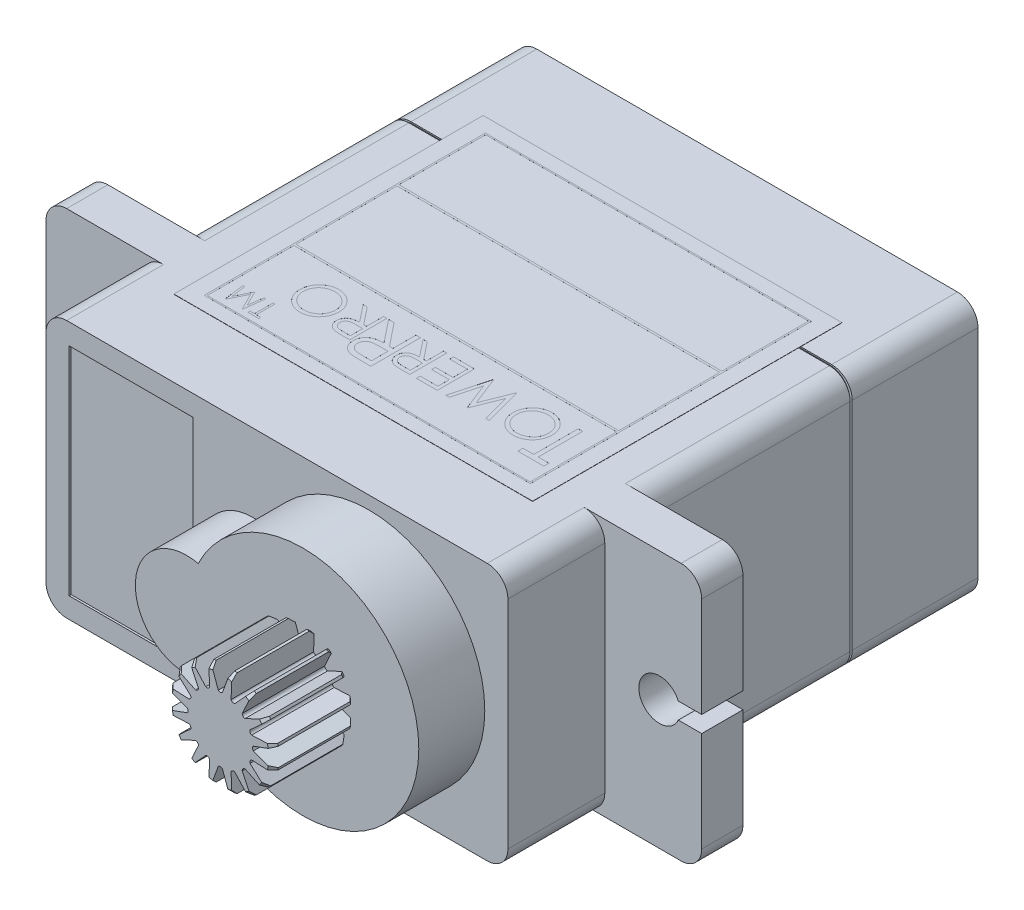
from build123d import *

# Parameters (mm, degrees)
IZIM1_W                      = 22.4
IZIM1_H                      = 12.5
IZIM1_W_2                    = 20.16
IZIM1_H_2                    = 11.25
Y_KSEKLIK_EKSTR_ZYON1_DEPTH  = 16.1
IZIM2_W                      = 22.4
IZIM2_H                      = 12.5
IZIM2_W_2                    = 20.16
IZIM2_H_2                    = 11.25
Y_KSEKLIK_EKSTR_ZYON2_DEPTH  = 6.7
Y_KSEKLIK_EKSTR_ZYON3_DEPTH  = 2
Y_KSEKLIK_EKSTR_ZYON4_DEPTH  = 26
IZIM4_W                      = 20.16
IZIM4_H                      = 11.25
KES_EKSTR_ZYON1_DEPTH        = 32
IZIM4_2_W                    = 20.16
IZIM4_2_H                    = 11.25
Y_KSEKLIK_EKSTR_ZYON5_DEPTH  = 2
IZIM6_W                      = 6
IZIM6_H                      = 10.5
KES_EKSTR_ZYON2_DEPTH        = 0.1
Y_KSEKLIK_EKSTR_ZYON6_START  = -0.1
IZIM7_W                      = 20.16
IZIM7_H                      = 11.25
Y_KSEKLIK_EKSTR_ZYON6_DEPTH  = 2
RADYUS1_R                    = 1
KES_EKSTR_ZYON3_START        = -6
KES_EKSTR_ZYON3_DEPTH        = 0.1
IZIM10_W                     = 17.4
IZIM10_H                     = 2.1
Y_KSEKLIK_EKSTR_ZYON7_DEPTH  = 0.01
IZIM11_W                     = 15.8166
IZIM11_H                     = 13.635
IZIM11_W_2                   = 15.66
IZIM11_H_2                   = 4.2
IZIM11_H_3                   = 4.9
Y_KSEKLIK_EKSTR_ZYON8_DEPTH  = 0.001
KES_EKSTR_ZYON4_DEPTH        = 0.001
IZIM13_R                     = 0.5
Y_KSEKLIK_EKSTR_ZYON9_DEPTH  = 3.8
IZIM15_R                     = 2.6
Y_KSEKLIK_EKSTR_ZYON10_DEPTH = 4
PAH1_SIZE                    = 0.25
CUT_EXTRUDE4_DEPTH           = 4
CIRPATTERN1_COUNT            = 16


with BuildPart() as part:
    # izim1 → Y_kseklik-Ekstr_zyon1 (new body)
    with BuildSketch(Plane.XY):
        with Locations((11.2, 6.25)):
            Rectangle(IZIM1_W, IZIM1_H)
        with Locations((11.2, 6.25)):
            Rectangle(IZIM1_W_2, IZIM1_H_2, mode=Mode.SUBTRACT)
    extrude(amount=Y_KSEKLIK_EKSTR_ZYON1_DEPTH)

    # izim2 → Y_kseklik-Ekstr_zyon2 (add)
    with BuildSketch(Plane.XY.offset(16.1)):
        with Locations((11.2, 6.25)):
            Rectangle(IZIM2_W, IZIM2_H)
        with Locations((11.2, 6.25)):
            Rectangle(IZIM2_W_2, IZIM2_H_2, mode=Mode.SUBTRACT)
    extrude(amount=Y_KSEKLIK_EKSTR_ZYON2_DEPTH)

    # izim2_5 → Y_kseklik-Ekstr_zyon3 (add)
    with BuildSketch(Plane.XY.offset(16.1)):
        with BuildLine():
            ThreePointArc((-3.566709048, 5.85), (-1.649822276, 6.25), (-3.566709048, 6.65))
            Line((-3.566709048, 6.65), (-4.7, 6.65))
            Line((-4.7, 6.65), (-4.7, 12.5))
            Line((-4.7, 12.5), (0, 12.5))
            Line((0, 12.5), (0, 0))
            Line((0, 0), (-4.7, 0))
            Line((-4.7, 0), (-4.7, 5.85))
            Line((-4.7, 5.85), (-3.566709048, 5.85))
        make_face()
        with BuildLine():
            Line((27.1, 5.85), (25.966709048, 5.85))
            ThreePointArc((25.966709048, 5.85), (24.049822276, 6.25), (25.966709048, 6.65))
            Line((25.966709048, 6.65), (27.1, 6.65))
            Line((27.1, 6.65), (27.1, 12.5))
            Line((27.1, 12.5), (22.4, 12.5))
            Line((22.4, 12.5), (22.4, 0))
            Line((22.4, 0), (27.1, 0))
            Line((27.1, 0), (27.1, 5.85))
        make_face()
    extrude(amount=Y_KSEKLIK_EKSTR_ZYON3_DEPTH)



with BuildPart() as body_2:
    # izim3 → Y_kseklik-Ekstr_zyon4 (new body)
    with BuildSketch(Plane(origin=(0, 0, 0), x_dir=(-1, 0, 0), z_dir=(0, 0, -1))):
        with BuildLine():
            ThreePointArc((-10.583916669, 8.684078645), (-21.28, 6.25), (-10.583916669, 3.815921355))
            ThreePointArc((-10.583916669, 3.815921355), (-7.533690219, 6.25), (-10.583916669, 8.684078645))
        make_face()
    extrude(amount=-Y_KSEKLIK_EKSTR_ZYON4_DEPTH)

    # izim4 → Kes-Ekstr_zyon1 (cut)
    with BuildSketch(Plane.XY.offset(22.8)):
        with Locations((11.2, 6.25)):
            Rectangle(IZIM4_W, IZIM4_H)
    extrude(amount=-KES_EKSTR_ZYON1_DEPTH, mode=Mode.SUBTRACT)


with BuildPart() as part_1:
    add(part.part)

    add(body_2.part)  # Y_kseklik-Ekstr_zyon5 merges body 2
    # izim4_2 → Y_kseklik-Ekstr_zyon5 (add)
    with BuildSketch(Plane.XY.offset(22.8)):
        with Locations((11.2, 6.25)):
            Rectangle(IZIM4_2_W, IZIM4_2_H)
    extrude(amount=-Y_KSEKLIK_EKSTR_ZYON5_DEPTH)

    # izim6 → Kes-Ekstr_zyon2 (cut)
    with BuildSketch(Plane.XY.offset(22.8)):
        with Locations((4.120596884, 6.247127185)):
            Rectangle(IZIM6_W, IZIM6_H)
    extrude(amount=-KES_EKSTR_ZYON2_DEPTH, mode=Mode.SUBTRACT)

    # izim7 → Y_kseklik-Ekstr_zyon6 (add)
    with BuildSketch(Plane(origin=(0, 0, 0), x_dir=(-1, 0, 0), z_dir=(0, 0, -1)).offset(Y_KSEKLIK_EKSTR_ZYON6_START)):
        with Locations((-11.2, 6.25)):
            Rectangle(IZIM7_W, IZIM7_H)
    extrude(amount=-Y_KSEKLIK_EKSTR_ZYON6_DEPTH)

    # Radyus1
    radyus1_edges = [part_1.edges().sort_by_distance(p)[0] for p in [
        (0, 0, 8.05),
        (0, 12.5, 8.05),
        (-4.7, 0, 17.1),
        (-4.7, 12.5, 17.1),
        (22.4, 12.5, 8.05),
        (22.4, 0, 8.05),
        (0, 12.5, 20.45),
        (22.4, 12.5, 20.45),
        (22.4, 0, 20.45),
        (27.1, 12.5, 17.1),
        (0, 0, 20.45),
        (27.1, 0, 17.1),
    ]]
    fillet(radyus1_edges, radius=RADYUS1_R)

    # izim9 → Kes-Ekstr_zyon3 (cut)
    with BuildSketch(Plane(origin=(0, 0, 0.1), x_dir=(-1, 0, 0), z_dir=(0, 0, -1)).offset(KES_EKSTR_ZYON3_START)):
        with BuildLine():
            Line((-21.4, 12.5), (-1, 12.5))
            ThreePointArc((-1, 12.5), (-0.292893219, 12.207106781), (0, 11.5))
            Line((0, 11.5), (0, 1))
            ThreePointArc((0, 1), (-0.292893219, 0.292893219), (-1, 0))
            Line((-1, 0), (-21.4, 0))
            ThreePointArc((-21.4, 0), (-22.107106781, 0.292893219), (-22.4, 1))
            Line((-22.4, 1), (-22.4, 11.5))
            ThreePointArc((-22.4, 11.5), (-22.107106781, 12.207106781), (-21.4, 12.5))
        make_face()
        with BuildLine():
            Line((-22.288, 1.0525), (-22.288, 11.4475))
            ThreePointArc((-22.288, 11.4475), (-21.998035713, 12.147535713), (-21.298, 12.4375))
            Line((-21.298, 12.4375), (-1.102, 12.4375))
            ThreePointArc((-1.102, 12.4375), (-0.401964287, 12.147535713), (-0.112, 11.4475))
            Line((-0.112, 11.4475), (-0.112, 1.0525))
            ThreePointArc((-0.112, 1.0525), (-0.401964287, 0.352464287), (-1.102, 0.0625))
            Line((-1.102, 0.0625), (-21.298, 0.0625))
            ThreePointArc((-21.298, 0.0625), (-21.998035713, 0.352464287), (-22.288, 1.0525))
        make_face(mode=Mode.SUBTRACT)
    extrude(amount=-KES_EKSTR_ZYON3_DEPTH, mode=Mode.SUBTRACT)

    # izim10 → Y_kseklik-Ekstr_zyon7 (add)
    with BuildSketch(Plane(origin=(0, 12.5, 0), x_dir=(1, 0, 0), z_dir=(0, 1, 0))):
        Polygon((2.5, -19.1), (19.9, -19.1), (19.9, -18.1), (19.9, -6.2), (2.5, -6.2), align=None)
        with Locations((11.2, -5.15)):
            Rectangle(IZIM10_W, IZIM10_H)
    extrude(amount=Y_KSEKLIK_EKSTR_ZYON7_DEPTH)

    # izim11 → Y_kseklik-Ekstr_zyon8 (add)
    with BuildSketch(Plane(origin=(0, 12.51, 0), x_dir=(1, 0, 0), z_dir=(0, 1, 0))):
        with Locations((11.2, -11.6)):
            Rectangle(IZIM11_W, IZIM11_H)
        with Locations((11.2, -16.25)):
            Rectangle(IZIM11_W_2, IZIM11_H_2, mode=Mode.SUBTRACT)
        with Locations((11.2, -6.95)):
            Rectangle(IZIM11_W_2, IZIM11_H_2, mode=Mode.SUBTRACT)
        with Locations((11.2, -11.6)):
            Rectangle(IZIM11_W_2, IZIM11_H_3, mode=Mode.SUBTRACT)
    extrude(amount=Y_KSEKLIK_EKSTR_ZYON8_DEPTH)

    # izim12 → Kes-Ekstr_zyon4 (cut)
    with BuildSketch(Plane(origin=(0, 12.51, 0), x_dir=(1, 0, 0), z_dir=(0, 1, 0))):
        Polygon((18.179849752, -17.10955999), (18.702926675, -17.10955999), (18.702926675, -17.355713837), (17.441388213, -17.355713837), (17.441388213, -17.10955999), (17.964465136, -17.10955999), (17.964465136, -14.955713837), (18.179849752, -14.955713837), align=None)
        with BuildLine():
            add(Edge.make_bspline(
                [(17.596123598, -15.847781144), (17.596600402, -15.890352652), (17.592054157, -15.953769235), (17.579172047, -16.037109108), (17.565460452, -16.098068862), (17.547741173, -16.157819698), (17.525913504, -16.216240052), (17.500896874, -16.27381097), (17.47111171, -16.329436818), (17.438615056, -16.383204893), (17.40318076, -16.434442874), (17.36456171, -16.482235511), (17.323309582, -16.527350755), (17.278853352, -16.569018591), (17.231862086, -16.608147478), (17.182089902, -16.644332354), (17.129458087, -16.676813285), (17.075308504, -16.706647276), (17.019248311, -16.731556708), (16.962460266, -16.753571424), (16.904444362, -16.771073448), (16.845334046, -16.784976123), (16.764497886, -16.797770734), (16.702885675, -16.802359627), (16.661508214, -16.801867683)],
                knots=[0, 0, 0, 0, 0.085881169, 0.128132386, 0.170168405, 0.211938097, 0.253861187, 0.296020311, 0.338574299, 0.381150423, 0.422820599, 0.464244847, 0.505120974, 0.546150251, 0.587164454, 0.62852183, 0.670271074, 0.711969505, 0.753242069, 0.794029495, 0.834869589, 0.875486283, 0.916539236, 1, 1, 1, 1], degree=3))
            add(Edge.make_bspline(
                [(16.661508214, -16.801867683), (16.59608632, -16.801676694), (16.499095745, -16.794133942), (16.374523585, -16.765278498), (16.28650177, -16.735345664), (16.202847856, -16.696490934), (16.123298834, -16.649331281), (16.048127766, -16.593391403), (15.977529104, -16.530002392), (15.913361965, -16.460324424), (15.857525352, -16.385520266), (15.810006102, -16.307095468), (15.771170508, -16.224539268), (15.740694657, -16.138220427), (15.712097556, -16.015819013), (15.703687695, -15.920728943), (15.703815906, -15.85643499)],
                knots=[0, 0, 0, 0, 0.13073763, 0.193341164, 0.25498957, 0.316108392, 0.377251257, 0.43938486, 0.502966344, 0.566515184, 0.628263548, 0.689117745, 0.749366545, 0.810186161, 0.871621029, 1, 1, 1, 1], degree=3))
            add(Edge.make_bspline(
                [(15.703815906, -15.85643499), (15.703693647, -15.792625776), (15.712093484, -15.698110766), (15.740788506, -15.576521041), (15.770793046, -15.490327904), (15.809657294, -15.40793808), (15.8572513, -15.329458419), (15.912962472, -15.25443614), (15.976866522, -15.184418979), (16.046650505, -15.120245908), (16.120992518, -15.063515201), (16.199802813, -15.016257957), (16.281851761, -14.97684261), (16.36795434, -14.947026989), (16.488998428, -14.917475402), (16.583439396, -14.909591987), (16.647085137, -14.90955999)],
                knots=[0, 0, 0, 0, 0.128576319, 0.190331218, 0.251392307, 0.312186107, 0.37359078, 0.436091904, 0.500231152, 0.564354845, 0.626953074, 0.688357747, 0.749255231, 0.810087631, 0.871663616, 1, 1, 1, 1], degree=3))
            add(Edge.make_bspline(
                [(16.647085137, -14.90955999), (16.711376806, -14.909424964), (16.806590582, -14.917865065), (16.929052902, -14.946469582), (17.015705008, -14.976547628), (17.098377514, -15.015325029), (17.177062189, -15.062963513), (17.25185363, -15.119102379), (17.32199081, -15.182956243), (17.386086472, -15.252606418), (17.442463171, -15.326850795), (17.489826856, -15.404983364), (17.528621071, -15.486681964), (17.559263944, -15.571735652), (17.587693085, -15.691760407), (17.59632315, -15.784906211), (17.596123598, -15.847781144)],
                knots=[0, 0, 0, 0, 0.129754547, 0.192083828, 0.253475092, 0.314589033, 0.376095281, 0.438844932, 0.503090279, 0.567320043, 0.629681905, 0.690980548, 0.751436286, 0.811992743, 0.87314184, 1, 1, 1, 1], degree=3))
        make_face()
        with BuildLine():
            add(Edge.make_bspline(
                [(15.865354368, -15.856795567), (15.864899048, -15.89141212), (15.868641252, -15.942755255), (15.879171493, -16.010004715), (15.890346538, -16.058689287), (15.904776872, -16.106054156), (15.922563437, -16.152055361), (15.943539052, -16.196864151), (15.967611793, -16.240369751), (15.99467128, -16.28211691), (16.024240123, -16.322026161), (16.056826592, -16.359351378), (16.091508167, -16.395001393), (16.129118664, -16.42826316), (16.169664675, -16.459008053), (16.212136541, -16.48862175), (16.257495186, -16.514828979), (16.304137663, -16.539157113), (16.352047102, -16.559895927), (16.400624452, -16.57780924), (16.449934394, -16.592104184), (16.49989249, -16.60342163), (16.567632767, -16.613847542), (16.619073115, -16.617732743), (16.653575522, -16.617252298)],
                knots=[0, 0, 0, 0, 0.085123374, 0.126463518, 0.167440062, 0.207960217, 0.248230142, 0.288727612, 0.329644311, 0.370508574, 0.411096706, 0.451783902, 0.492367721, 0.533444523, 0.575218486, 0.617559484, 0.66078721, 0.704052373, 0.746976364, 0.789184872, 0.831405817, 0.873247812, 0.915172343, 1, 1, 1, 1], degree=3))
            add(Edge.make_bspline(
                [(16.653575522, -16.617252298), (16.687597892, -16.617729343), (16.738323725, -16.61385477), (16.805096503, -16.603410733), (16.854236619, -16.592166296), (16.902663877, -16.577730089), (16.950432748, -16.559910889), (16.997585697, -16.539106248), (17.043691586, -16.514957261), (17.088014073, -16.487888616), (17.130819477, -16.459349311), (17.170473007, -16.427721735), (17.207740586, -16.394178764), (17.242531795, -16.358258555), (17.274851287, -16.320225718), (17.304667209, -16.279908069), (17.331622211, -16.237473595), (17.355609865, -16.193158656), (17.377087479, -16.147810533), (17.39488998, -16.10089618), (17.40899825, -16.052708629), (17.420949959, -16.003459246), (17.431151996, -15.935388431), (17.435136733, -15.883495399), (17.434585137, -15.848502298)],
                knots=[0, 0, 0, 0, 0.083634277, 0.124967906, 0.166226326, 0.207589577, 0.24923634, 0.291611976, 0.334345341, 0.377209532, 0.419377167, 0.46085975, 0.501906639, 0.542695883, 0.583825813, 0.624645074, 0.666000921, 0.707429689, 0.748581948, 0.789397994, 0.830761245, 0.872086406, 0.914004329, 1, 1, 1, 1], degree=3))
            add(Edge.make_bspline(
                [(17.434585137, -15.848502298), (17.434750827, -15.797346282), (17.42762467, -15.721663344), (17.403842094, -15.624244722), (17.378499799, -15.555401087), (17.346126628, -15.489531054), (17.306649283, -15.426890951), (17.259693895, -15.367499274), (17.206388879, -15.311798069), (17.148101031, -15.26097781), (17.086237636, -15.216305818), (17.021288072, -15.178711215), (16.953626686, -15.147273412), (16.882675875, -15.123624642), (16.783067773, -15.100683796), (16.705786175, -15.09374018), (16.653575522, -15.094175375)],
                knots=[0, 0, 0, 0, 0.1268942, 0.187738963, 0.248419712, 0.308585774, 0.369580252, 0.4318217, 0.49617186, 0.56065739, 0.623491454, 0.685244918, 0.746642893, 0.808335087, 0.870491415, 1, 1, 1, 1], degree=3))
            add(Edge.make_bspline(
                [(16.653575522, -15.094175375), (16.61827604, -15.094022944), (16.565574476, -15.097066102), (16.496405554, -15.107625162), (16.445877829, -15.11893103), (16.396319697, -15.132912391), (16.347883036, -15.150252338), (16.300575356, -15.171030097), (16.254196299, -15.194223032), (16.209750432, -15.220380406), (16.167742487, -15.249120925), (16.127896212, -15.279675067), (16.090696657, -15.312975122), (16.056050694, -15.348592326), (16.024308826, -15.386786075), (15.994506805, -15.426801694), (15.967740863, -15.469225384), (15.943424136, -15.513189671), (15.922577474, -15.558669814), (15.904764642, -15.605377795), (15.890402682, -15.653359562), (15.879163004, -15.702504585), (15.868647916, -15.7702394), (15.864895994, -15.821938569), (15.865354368, -15.856795567)],
                knots=[0, 0, 0, 0, 0.086551414, 0.129197693, 0.17146334, 0.213449527, 0.255404662, 0.297514824, 0.340092799, 0.382506193, 0.423874281, 0.464849866, 0.505557411, 0.546205151, 0.586586979, 0.627264633, 0.668477012, 0.709503453, 0.750388823, 0.791063273, 0.832000674, 0.873115963, 0.914597308, 1, 1, 1, 1], degree=3))
        make_face(mode=Mode.SUBTRACT)
        Polygon((14.971123598, -14.955713837), (15.449969752, -16.755713837), (15.283022637, -16.755713837), (14.930738983, -15.435641721), (14.406820714, -16.755713837), (14.383383214, -16.755713837), (13.869200522, -15.444656144), (13.515113983, -16.755713837), (13.349969752, -16.755713837), (13.835306291, -14.955713837), (13.858383214, -14.955713837), (14.399969752, -16.332396529), (14.948046675, -14.955713837), align=None)
        with BuildLine():
            add(Edge.make_bspline(
                [(10.465354368, -16.274343644), (10.465189989, -16.227635019), (10.473145061, -16.158297078), (10.503865997, -16.072287335), (10.534861708, -16.013582039), (10.574363542, -15.960636885), (10.621823521, -15.914291239), (10.677012671, -15.875150095), (10.728630628, -15.84829584), (10.774249019, -15.831016684), (10.811915131, -15.818797881), (10.853033693, -15.809516904), (10.897014812, -15.801080167), (10.944198112, -15.794648697), (11.01328896, -15.788337765), (11.066890039, -15.78659066), (11.103575522, -15.786483067)],
                knots=[0, 0, 0, 0, 0.153710705, 0.226698871, 0.29917182, 0.371165996, 0.44297777, 0.516334013, 0.592857108, 0.63351018, 0.676623617, 0.722915422, 0.771971354, 0.823829257, 0.87938645, 1, 1, 1, 1], degree=3))
            Line((11.103575522, -15.786483067), (10.442277445, -14.955713837))
            Line((10.442277445, -14.955713837), (10.64203706, -14.955713837))
            Line((10.64203706, -14.955713837), (11.303335137, -15.786483067))
            Line((11.303335137, -15.786483067), (11.434585137, -15.786483067))
            Line((11.434585137, -15.786483067), (11.434585137, -14.955713837))
            Line((11.434585137, -14.955713837), (11.596123598, -14.955713837))
            Line((11.596123598, -14.955713837), (11.596123598, -16.755713837))
            Line((11.596123598, -16.755713837), (11.235907252, -16.755713837))
            add(Edge.make_bspline(
                [(11.235907252, -16.755713837), (11.189760123, -16.755451111), (11.123608965, -16.75559758), (11.039506977, -16.75216837), (10.985495991, -16.750058171), (10.937561911, -16.746191856), (10.885537282, -16.741684066), (10.849744501, -16.736038609), (10.828094752, -16.731194606)],
                knots=[0, 0, 0, 0, 0.338434414, 0.484822051, 0.617157578, 0.734698361, 0.837385184, 1, 1, 1, 1], degree=3))
            add(Edge.make_bspline(
                [(10.828094752, -16.731194606), (10.801872887, -16.725439568), (10.76375897, -16.713411311), (10.715594154, -16.692152244), (10.681711667, -16.673551494), (10.649724976, -16.652361866), (10.619632121, -16.628519726), (10.591837976, -16.601815035), (10.565353271, -16.573355533), (10.542227155, -16.541901713), (10.521407246, -16.509049879), (10.503930621, -16.474167535), (10.490174818, -16.437430581), (10.478656937, -16.399199559), (10.468106092, -16.344907519), (10.465222935, -16.302809433), (10.465354368, -16.274343644)],
                knots=[0, 0, 0, 0, 0.12703991, 0.188709102, 0.249085329, 0.309868062, 0.370230871, 0.430628561, 0.492276732, 0.55409549, 0.615218447, 0.676314893, 0.738476023, 0.800795937, 0.865209823, 1, 1, 1, 1], degree=3))
        make_face()
        with BuildLine():
            add(Edge.make_bspline(
                [(10.626892829, -16.274704221), (10.626873406, -16.303358273), (10.633158935, -16.34636952), (10.655335081, -16.399629942), (10.677889507, -16.436870532), (10.706000823, -16.470425745), (10.738734025, -16.499048155), (10.775330144, -16.522826897), (10.809256533, -16.53851616), (10.839802364, -16.547747739), (10.866201438, -16.55444897), (10.896290206, -16.55914204), (10.929714534, -16.56345918), (10.966621188, -16.567111879), (11.022753005, -16.570498106), (11.06666957, -16.571204174), (11.097085137, -16.571098452)],
                knots=[0, 0, 0, 0, 0.136311338, 0.203719134, 0.273224715, 0.34260796, 0.411061944, 0.479238515, 0.549585203, 0.587913733, 0.630891961, 0.67900679, 0.732608365, 0.791193356, 0.855339952, 1, 1, 1, 1], degree=3))
            Line((11.097085137, -16.571098452), (11.434585137, -16.571098452))
            Line((11.434585137, -16.571098452), (11.434585137, -15.971098452))
            Line((11.434585137, -15.971098452), (11.105017829, -15.968574413))
            add(Edge.make_bspline(
                [(11.105017829, -15.968574413), (11.075185043, -15.968095295), (11.032015747, -15.969678106), (10.976480181, -15.972950808), (10.939430828, -15.976517902), (10.905490324, -15.981123667), (10.8746809, -15.986891229), (10.846934522, -15.993582833), (10.81467714, -16.004045496), (10.778242556, -16.019907008), (10.739462067, -16.044501622), (10.705552361, -16.074245247), (10.677350199, -16.108686551), (10.654734631, -16.146717654), (10.633461262, -16.20145847), (10.626604937, -16.245257156), (10.626892829, -16.274704221)],
                knots=[0, 0, 0, 0, 0.138878011, 0.201133482, 0.259058627, 0.312175748, 0.360589919, 0.404983277, 0.444988631, 0.518418117, 0.589382616, 0.65799459, 0.727585942, 0.795840798, 0.863196901, 1, 1, 1, 1], degree=3))
        make_face(mode=Mode.SUBTRACT)
        with BuildLine():
            add(Edge.make_bspline(
                [(8.804135606, -16.713886913), (8.803916434, -16.651608746), (8.814523197, -16.559158159), (8.855484445, -16.444478502), (8.89681206, -16.366204773), (8.949481171, -16.295611235), (9.012761144, -16.233817039), (9.086346678, -16.181628848), (9.15517062, -16.145823174), (9.215995141, -16.1227843), (9.266216624, -16.106492562), (9.321041373, -16.094117926), (9.379682865, -16.082868944), (9.442593931, -16.074293651), (9.534715063, -16.065879074), (9.606183168, -16.063549601), (9.655097144, -16.063406144)],
                knots=[0, 0, 0, 0, 0.153710705, 0.226698871, 0.29917182, 0.371165996, 0.44297777, 0.516334013, 0.592857108, 0.63351018, 0.676623617, 0.722915422, 0.771971354, 0.823829257, 0.87938645, 1, 1, 1, 1], degree=3))
            Line((9.655097144, -16.063406144), (8.773366375, -14.955713837))
            Line((8.773366375, -14.955713837), (9.039712529, -14.955713837))
            Line((9.039712529, -14.955713837), (9.921443298, -16.063406144))
            Line((9.921443298, -16.063406144), (10.096443298, -16.063406144))
            Line((10.096443298, -16.063406144), (10.096443298, -14.955713837))
            Line((10.096443298, -14.955713837), (10.311827914, -14.955713837))
            Line((10.311827914, -14.955713837), (10.311827914, -17.355713837))
            Line((10.311827914, -17.355713837), (9.831539452, -17.355713837))
            add(Edge.make_bspline(
                [(9.831539452, -17.355713837), (9.770009947, -17.355363536), (9.681808403, -17.355558827), (9.569672418, -17.350986548), (9.497657771, -17.34817295), (9.433745664, -17.343017863), (9.364379492, -17.337007476), (9.316655783, -17.329480199), (9.287789452, -17.323021529)],
                knots=[0, 0, 0, 0, 0.338434414, 0.484822051, 0.617157578, 0.734698361, 0.837385184, 1, 1, 1, 1], degree=3))
            add(Edge.make_bspline(
                [(9.287789452, -17.323021529), (9.252826965, -17.315348145), (9.202008409, -17.299310469), (9.137788655, -17.270965047), (9.092612006, -17.246164046), (9.049963083, -17.217911209), (9.009839277, -17.18612169), (8.972780417, -17.150515434), (8.937467477, -17.112569432), (8.906632655, -17.070631005), (8.878872777, -17.02682856), (8.85557061, -16.980318768), (8.83722954, -16.931336163), (8.821872365, -16.880361466), (8.807804572, -16.80797208), (8.803960363, -16.751841298), (8.804135606, -16.713886913)],
                knots=[0, 0, 0, 0, 0.12703991, 0.188709102, 0.249085329, 0.309868062, 0.370230871, 0.430628561, 0.492276732, 0.55409549, 0.615218447, 0.676314893, 0.738476023, 0.800795937, 0.865209823, 1, 1, 1, 1], degree=3))
        make_face()
        with BuildLine():
            add(Edge.make_bspline(
                [(9.019520221, -16.714367683), (9.019494323, -16.752573085), (9.02787503, -16.809921414), (9.057443223, -16.88093531), (9.087515792, -16.930589431), (9.124997547, -16.975329715), (9.168641816, -17.013492928), (9.217436641, -17.045197918), (9.262671827, -17.066116935), (9.303399601, -17.078425706), (9.338598367, -17.087360681), (9.378716724, -17.093618108), (9.423282494, -17.099374294), (9.472491366, -17.104244559), (9.547333789, -17.108759529), (9.60588921, -17.109700953), (9.646443298, -17.10955999)],
                knots=[0, 0, 0, 0, 0.136311338, 0.203719134, 0.273224715, 0.34260796, 0.411061944, 0.479238515, 0.549585203, 0.587913733, 0.630891961, 0.67900679, 0.732608365, 0.791193356, 0.855339952, 1, 1, 1, 1], degree=3))
            Line((9.646443298, -17.10955999), (10.096443298, -17.10955999))
            Line((10.096443298, -17.10955999), (10.096443298, -16.30955999))
            Line((10.096443298, -16.30955999), (9.657020221, -16.306194606))
            add(Edge.make_bspline(
                [(9.657020221, -16.306194606), (9.617243174, -16.305555781), (9.559684112, -16.307666196), (9.48563669, -16.312029799), (9.436237554, -16.316785923), (9.390983548, -16.322926944), (9.349904315, -16.330617027), (9.312909146, -16.339539166), (9.269899303, -16.353489383), (9.221319857, -16.374638065), (9.169612538, -16.407430884), (9.124399597, -16.44708905), (9.086796714, -16.49301079), (9.056642623, -16.543718926), (9.028278132, -16.616706682), (9.019136365, -16.675104929), (9.019520221, -16.714367683)],
                knots=[0, 0, 0, 0, 0.138878011, 0.201133482, 0.259058627, 0.312175748, 0.360589919, 0.404983277, 0.444988631, 0.518418117, 0.589382616, 0.65799459, 0.727585942, 0.795840798, 0.863196901, 1, 1, 1, 1], degree=3))
        make_face(mode=Mode.SUBTRACT)
        with BuildLine():
            add(Edge.make_bspline(
                [(7.55766206, -16.274343644), (7.557497681, -16.227635019), (7.565452753, -16.158297078), (7.596173689, -16.072287335), (7.627169401, -16.013582039), (7.666671234, -15.960636885), (7.714131213, -15.914291239), (7.769320364, -15.875150095), (7.82093832, -15.84829584), (7.866556711, -15.831016684), (7.904222823, -15.818797881), (7.945341386, -15.809516904), (7.989322504, -15.801080167), (8.036505804, -15.794648697), (8.105596652, -15.788337765), (8.159197731, -15.78659066), (8.195883214, -15.786483067)],
                knots=[0, 0, 0, 0, 0.153710705, 0.226698871, 0.29917182, 0.371165996, 0.44297777, 0.516334013, 0.592857108, 0.63351018, 0.676623617, 0.722915422, 0.771971354, 0.823829257, 0.87938645, 1, 1, 1, 1], degree=3))
            Line((8.195883214, -15.786483067), (7.534585137, -14.955713837))
            Line((7.534585137, -14.955713837), (7.734344752, -14.955713837))
            Line((7.734344752, -14.955713837), (8.395642829, -15.786483067))
            Line((8.395642829, -15.786483067), (8.526892829, -15.786483067))
            Line((8.526892829, -15.786483067), (8.526892829, -14.955713837))
            Line((8.526892829, -14.955713837), (8.688431291, -14.955713837))
            Line((8.688431291, -14.955713837), (8.688431291, -16.755713837))
            Line((8.688431291, -16.755713837), (8.328214945, -16.755713837))
            add(Edge.make_bspline(
                [(8.328214945, -16.755713837), (8.282067816, -16.755451111), (8.215916658, -16.75559758), (8.131814669, -16.75216837), (8.077803684, -16.750058171), (8.029869604, -16.746191856), (7.977844974, -16.741684066), (7.942052193, -16.736038609), (7.920402445, -16.731194606)],
                knots=[0, 0, 0, 0, 0.338434414, 0.484822051, 0.617157578, 0.734698361, 0.837385184, 1, 1, 1, 1], degree=3))
            add(Edge.make_bspline(
                [(7.920402445, -16.731194606), (7.89418058, -16.725439568), (7.856066662, -16.713411311), (7.807901847, -16.692152244), (7.77401936, -16.673551494), (7.742032668, -16.652361866), (7.711939813, -16.628519726), (7.684145668, -16.601815035), (7.657660963, -16.573355533), (7.634534847, -16.541901713), (7.613714938, -16.509049879), (7.596238313, -16.474167535), (7.58248251, -16.437430581), (7.570964629, -16.399199559), (7.560413784, -16.344907519), (7.557530628, -16.302809433), (7.55766206, -16.274343644)],
                knots=[0, 0, 0, 0, 0.12703991, 0.188709102, 0.249085329, 0.309868062, 0.370230871, 0.430628561, 0.492276732, 0.55409549, 0.615218447, 0.676314893, 0.738476023, 0.800795937, 0.865209823, 1, 1, 1, 1], degree=3))
        make_face()
        with BuildLine():
            add(Edge.make_bspline(
                [(7.719200522, -16.274704221), (7.719181098, -16.303358273), (7.725466628, -16.34636952), (7.747642773, -16.399629942), (7.770197199, -16.436870532), (7.798308516, -16.470425745), (7.831041717, -16.499048155), (7.867637836, -16.522826897), (7.901564226, -16.53851616), (7.932110056, -16.547747739), (7.958509131, -16.55444897), (7.988597898, -16.55914204), (8.022022226, -16.56345918), (8.05892888, -16.567111879), (8.115060697, -16.570498106), (8.158977263, -16.571204174), (8.189392829, -16.571098452)],
                knots=[0, 0, 0, 0, 0.136311338, 0.203719134, 0.273224715, 0.34260796, 0.411061944, 0.479238515, 0.549585203, 0.587913733, 0.630891961, 0.67900679, 0.732608365, 0.791193356, 0.855339952, 1, 1, 1, 1], degree=3))
            Line((8.189392829, -16.571098452), (8.526892829, -16.571098452))
            Line((8.526892829, -16.571098452), (8.526892829, -15.971098452))
            Line((8.526892829, -15.971098452), (8.197325522, -15.968574413))
            add(Edge.make_bspline(
                [(8.197325522, -15.968574413), (8.167492736, -15.968095295), (8.12432344, -15.969678106), (8.068787873, -15.972950808), (8.031738521, -15.976517902), (7.997798017, -15.981123667), (7.966988592, -15.986891229), (7.939242215, -15.993582833), (7.906984833, -16.004045496), (7.870550248, -16.019907008), (7.831769759, -16.044501622), (7.797860053, -16.074245247), (7.769657891, -16.108686551), (7.747042323, -16.146717654), (7.725768955, -16.20145847), (7.718912629, -16.245257156), (7.719200522, -16.274704221)],
                knots=[0, 0, 0, 0, 0.138878011, 0.201133482, 0.259058627, 0.312175748, 0.360589919, 0.404983277, 0.444988631, 0.518418117, 0.589382616, 0.65799459, 0.727585942, 0.795840798, 0.863196901, 1, 1, 1, 1], degree=3))
        make_face(mode=Mode.SUBTRACT)
        with BuildLine():
            add(Edge.make_bspline(
                [(7.25766206, -15.847781144), (7.258138864, -15.890352652), (7.253592618, -15.953769235), (7.240710509, -16.037109108), (7.226998914, -16.098068862), (7.209279635, -16.157819698), (7.187451966, -16.216240052), (7.162435336, -16.27381097), (7.132650172, -16.329436818), (7.100153518, -16.383204893), (7.064719221, -16.434442874), (7.026100171, -16.482235511), (6.984848044, -16.527350755), (6.940391814, -16.569018591), (6.893400547, -16.608147478), (6.843628364, -16.644332354), (6.790996548, -16.676813285), (6.736846966, -16.706647276), (6.680786772, -16.731556708), (6.623998728, -16.753571424), (6.565982823, -16.771073448), (6.506872507, -16.784976123), (6.426036347, -16.797770734), (6.364424136, -16.802359627), (6.323046675, -16.801867683)],
                knots=[0, 0, 0, 0, 0.085881169, 0.128132386, 0.170168405, 0.211938097, 0.253861187, 0.296020311, 0.338574299, 0.381150423, 0.422820599, 0.464244847, 0.505120974, 0.546150251, 0.587164454, 0.62852183, 0.670271074, 0.711969505, 0.753242069, 0.794029495, 0.834869589, 0.875486283, 0.916539236, 1, 1, 1, 1], degree=3))
            add(Edge.make_bspline(
                [(6.323046675, -16.801867683), (6.257624782, -16.801676694), (6.160634206, -16.794133942), (6.036062047, -16.765278498), (5.948040232, -16.735345664), (5.864386317, -16.696490934), (5.784837296, -16.649331281), (5.709666227, -16.593391403), (5.639067565, -16.530002392), (5.574900426, -16.460324424), (5.519063814, -16.385520266), (5.471544563, -16.307095468), (5.43270897, -16.224539268), (5.402233119, -16.138220427), (5.373636017, -16.015819013), (5.365226157, -15.920728943), (5.365354368, -15.85643499)],
                knots=[0, 0, 0, 0, 0.13073763, 0.193341164, 0.25498957, 0.316108392, 0.377251257, 0.43938486, 0.502966344, 0.566515184, 0.628263548, 0.689117745, 0.749366545, 0.810186161, 0.871621029, 1, 1, 1, 1], degree=3))
            add(Edge.make_bspline(
                [(5.365354368, -15.85643499), (5.365232109, -15.792625776), (5.373631946, -15.698110766), (5.402326968, -15.576521041), (5.432331508, -15.490327904), (5.471195755, -15.40793808), (5.518789761, -15.329458419), (5.574500934, -15.25443614), (5.638404983, -15.184418979), (5.708188967, -15.120245908), (5.78253098, -15.063515201), (5.861341274, -15.016257957), (5.943390222, -14.97684261), (6.029492801, -14.947026989), (6.150536889, -14.917475402), (6.244977857, -14.909591987), (6.308623598, -14.90955999)],
                knots=[0, 0, 0, 0, 0.128576319, 0.190331218, 0.251392307, 0.312186107, 0.37359078, 0.436091904, 0.500231152, 0.564354845, 0.626953074, 0.688357747, 0.749255231, 0.810087631, 0.871663616, 1, 1, 1, 1], degree=3))
            add(Edge.make_bspline(
                [(6.308623598, -14.90955999), (6.372915268, -14.909424964), (6.468129043, -14.917865065), (6.590591363, -14.946469582), (6.67724347, -14.976547628), (6.759915975, -15.015325029), (6.838600651, -15.062963513), (6.913392091, -15.119102379), (6.983529271, -15.182956243), (7.047624934, -15.252606418), (7.104001633, -15.326850795), (7.151365317, -15.404983364), (7.190159532, -15.486681964), (7.220802405, -15.571735652), (7.249231547, -15.691760407), (7.257861611, -15.784906211), (7.25766206, -15.847781144)],
                knots=[0, 0, 0, 0, 0.129754547, 0.192083828, 0.253475092, 0.314589033, 0.376095281, 0.438844932, 0.503090279, 0.567320043, 0.629681905, 0.690980548, 0.751436286, 0.811992743, 0.87314184, 1, 1, 1, 1], degree=3))
        make_face()
        with BuildLine():
            add(Edge.make_bspline(
                [(5.526892829, -15.856795567), (5.526437509, -15.89141212), (5.530179714, -15.942755255), (5.540709954, -16.010004715), (5.551885, -16.058689287), (5.566315333, -16.106054156), (5.584101899, -16.152055361), (5.605077513, -16.196864151), (5.629150254, -16.240369751), (5.656209741, -16.28211691), (5.685778585, -16.322026161), (5.718365054, -16.359351378), (5.753046629, -16.395001393), (5.790657125, -16.42826316), (5.831203137, -16.459008053), (5.873675003, -16.48862175), (5.919033647, -16.514828979), (5.965676124, -16.539157113), (6.013585563, -16.559895927), (6.062162913, -16.57780924), (6.111472856, -16.592104184), (6.161430951, -16.60342163), (6.229171228, -16.613847542), (6.280611576, -16.617732743), (6.315113983, -16.617252298)],
                knots=[0, 0, 0, 0, 0.085123374, 0.126463518, 0.167440062, 0.207960217, 0.248230142, 0.288727612, 0.329644311, 0.370508574, 0.411096706, 0.451783902, 0.492367721, 0.533444523, 0.575218486, 0.617559484, 0.66078721, 0.704052373, 0.746976364, 0.789184872, 0.831405817, 0.873247812, 0.915172343, 1, 1, 1, 1], degree=3))
            add(Edge.make_bspline(
                [(6.315113983, -16.617252298), (6.349136354, -16.617729343), (6.399862186, -16.61385477), (6.466634965, -16.603410733), (6.51577508, -16.592166296), (6.564202338, -16.577730089), (6.611971209, -16.559910889), (6.659124158, -16.539106248), (6.705230048, -16.514957261), (6.749552534, -16.487888616), (6.792357939, -16.459349311), (6.832011469, -16.427721735), (6.869279047, -16.394178764), (6.904070257, -16.358258555), (6.936389748, -16.320225718), (6.96620567, -16.279908069), (6.993160672, -16.237473595), (7.017148326, -16.193158656), (7.038625941, -16.147810533), (7.056428441, -16.10089618), (7.070536712, -16.052708629), (7.08248842, -16.003459246), (7.092690457, -15.935388431), (7.096675195, -15.883495399), (7.096123598, -15.848502298)],
                knots=[0, 0, 0, 0, 0.083634277, 0.124967906, 0.166226326, 0.207589577, 0.24923634, 0.291611976, 0.334345341, 0.377209532, 0.419377167, 0.46085975, 0.501906639, 0.542695883, 0.583825813, 0.624645074, 0.666000921, 0.707429689, 0.748581948, 0.789397994, 0.830761245, 0.872086406, 0.914004329, 1, 1, 1, 1], degree=3))
            add(Edge.make_bspline(
                [(7.096123598, -15.848502298), (7.096289289, -15.797346282), (7.089163131, -15.721663344), (7.065380556, -15.624244722), (7.040038261, -15.555401087), (7.00766509, -15.489531054), (6.968187744, -15.426890951), (6.921232357, -15.367499274), (6.86792734, -15.311798069), (6.809639493, -15.26097781), (6.747776098, -15.216305818), (6.682826533, -15.178711215), (6.615165148, -15.147273412), (6.544214336, -15.123624642), (6.444606234, -15.100683796), (6.367324637, -15.09374018), (6.315113983, -15.094175375)],
                knots=[0, 0, 0, 0, 0.1268942, 0.187738963, 0.248419712, 0.308585774, 0.369580252, 0.4318217, 0.49617186, 0.56065739, 0.623491454, 0.685244918, 0.746642893, 0.808335087, 0.870491415, 1, 1, 1, 1], degree=3))
            add(Edge.make_bspline(
                [(6.315113983, -15.094175375), (6.279814501, -15.094022944), (6.227112938, -15.097066102), (6.157944015, -15.107625162), (6.10741629, -15.11893103), (6.057858159, -15.132912391), (6.009421498, -15.150252338), (5.962113817, -15.171030097), (5.91573476, -15.194223032), (5.871288893, -15.220380406), (5.829280948, -15.249120925), (5.789434674, -15.279675067), (5.752235119, -15.312975122), (5.717589156, -15.348592326), (5.685847287, -15.386786075), (5.656045267, -15.426801694), (5.629279324, -15.469225384), (5.604962598, -15.513189671), (5.584115935, -15.558669814), (5.566303104, -15.605377795), (5.551941144, -15.653359562), (5.540701466, -15.702504585), (5.530186378, -15.7702394), (5.526434456, -15.821938569), (5.526892829, -15.856795567)],
                knots=[0, 0, 0, 0, 0.086551414, 0.129197693, 0.17146334, 0.213449527, 0.255404662, 0.297514824, 0.340092799, 0.382506193, 0.423874281, 0.464849866, 0.505557411, 0.546205151, 0.586586979, 0.627264633, 0.668477012, 0.709503453, 0.750388823, 0.791063273, 0.832000674, 0.873115963, 0.914597308, 1, 1, 1, 1], degree=3))
        make_face(mode=Mode.SUBTRACT)
        Polygon((5.369681291, -17.967572811), (5.587630009, -17.967572811), (5.587630009, -18.070136913), (5.061988983, -18.070136913), (5.061988983, -17.967572811), (5.279937701, -17.967572811), (5.279937701, -17.070136913), (5.369681291, -17.070136913), align=None)
        Polygon((4.843439304, -17.070136913), (4.933783855, -17.070136913), (4.801772637, -18.070136913), (4.788952124, -18.070136913), (4.376091547, -17.249624093), (3.964232573, -18.070136913), (3.951211739, -18.070136913), (3.818399239, -17.070136913), (3.90854347, -17.070136913), (4.004296675, -17.789688196), (4.365274239, -17.070136913), (4.385506611, -17.070136913), (4.747886419, -17.79129076), align=None)
        Polygon((12.773046675, -16.017252298), (11.919200522, -16.017252298), (11.919200522, -15.832636913), (12.773046675, -15.832636913), (12.773046675, -15.140329221), (11.919200522, -15.140329221), (11.919200522, -14.955713837), (12.934585137, -14.955713837), (12.934585137, -16.755713837), (11.919200522, -16.755713837), (11.919200522, -16.571098452), (12.773046675, -16.571098452), align=None)
    extrude(amount=-KES_EKSTR_ZYON4_DEPTH, mode=Mode.SUBTRACT)

    # izim13 → Y_kseklik-Ekstr_zyon9 (add)
    with BuildSketch(Plane.XY.offset(26)):
        with Locations((15.655, 6.25)):
            Circle(IZIM13_R)
    extrude(amount=Y_KSEKLIK_EKSTR_ZYON9_DEPTH)


with BuildPart() as body_2_2:
    # izim15 → Y_kseklik-Ekstr_zyon10 (new body)
    with BuildSketch(Plane.XY.offset(26)):
        with Locations((15.655, 6.25)):
            Circle(IZIM15_R)
    extrude(amount=Y_KSEKLIK_EKSTR_ZYON10_DEPTH)

    # Pah1
    pah1_edges = [body_2_2.edges().sort_by_distance(p)[0] for p in [
        (13.055, 6.25, 26),
        (13.055, 6.25, 30),
    ]]
    chamfer(pah1_edges, length=PAH1_SIZE)

    # Sketch7 → Cut-Extrude4 (cut)
    with BuildSketch(Plane.XY.offset(30)):
        with BuildLine():
            ThreePointArc((15.292272674, 8.571837395), (15.473090514, 8.59294877), (15.655, 8.6))
            Line((15.655, 8.6), (15.655, 8.85))
            ThreePointArc((15.655, 8.85), (15.429294268, 8.840184727), (15.205292661, 8.810813017))
            Line((15.205292661, 8.810813017), (15.292272674, 8.571837395))
        make_face()
        with BuildLine():
            Line((15.655, 8.85), (15.655, 8.6))
            ThreePointArc((15.655, 8.6), (15.836909486, 8.59294877), (16.017727326, 8.571837395))
            Line((16.017727326, 8.571837395), (16.104707339, 8.810813017))
            ThreePointArc((16.104707339, 8.810813017), (15.880705732, 8.840184727), (15.655, 8.85))
        make_face()
        with BuildLine():
            ThreePointArc((15.555, 7.85), (15.60088039, 7.819343704), (15.655, 7.808578644))
            Line((15.655, 7.808578644), (15.655, 8.6))
            ThreePointArc((15.655, 8.6), (15.473090514, 8.59294877), (15.292272674, 8.571837395))
            Line((15.292272674, 8.571837395), (15.555, 7.85))
        make_face()
        with BuildLine():
            Line((15.655, 8.6), (15.655, 7.808578644))
            ThreePointArc((15.655, 7.808578644), (15.70911961, 7.819343704), (15.755, 7.85))
            Line((15.755, 7.85), (16.017727326, 8.571837395))
            ThreePointArc((16.017727326, 8.571837395), (15.836909486, 8.59294877), (15.655, 8.6))
        make_face()
    cut_extrude4 = extrude(amount=-CUT_EXTRUDE4_DEPTH, mode=Mode.SUBTRACT)

    # CirPattern1: Cut-Extrude4 ×16 about axis
    cirpattern1_axis = Axis((15.655, 6.25, 0), (0, 0, 1))
    for i in range(1, CIRPATTERN1_COUNT):
        add(cut_extrude4.rotate(cirpattern1_axis, i * 360 / CIRPATTERN1_COUNT), mode=Mode.SUBTRACT)


solid = Compound([part_1.part, body_2_2.part])
